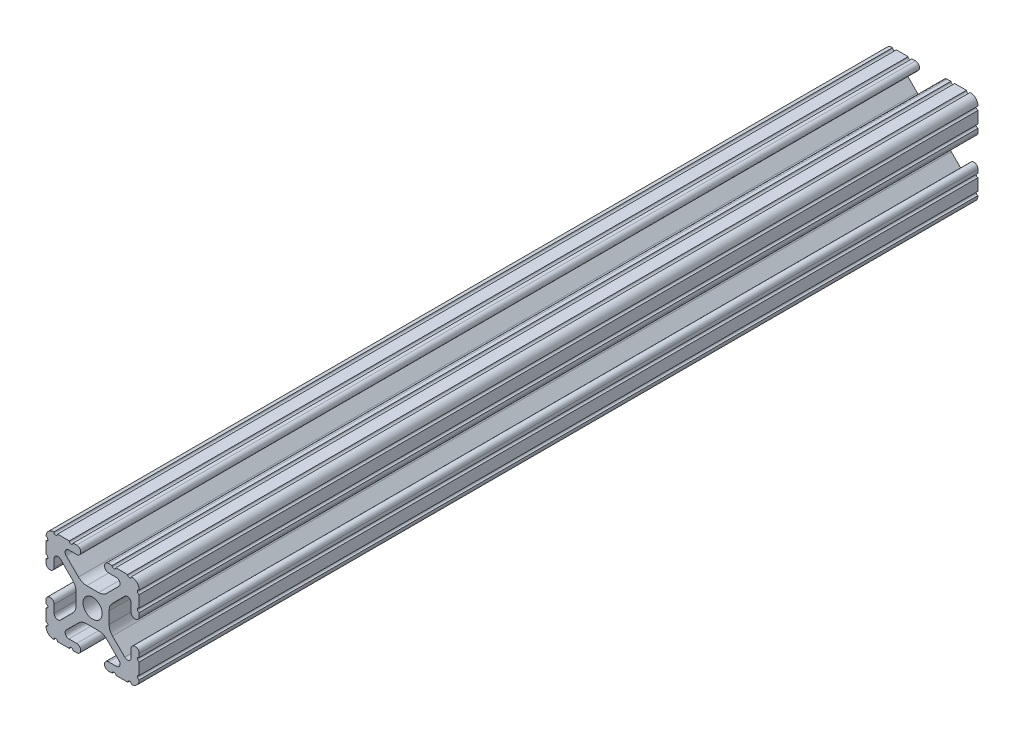
from build123d import *

# Parameters (mm, degrees)
SKETCH1_R           = 2.6035
BOSS_EXTRUDE1_DEPTH = 228.6


with BuildPart() as part:
    # Sketch1 → Boss-Extrude1 (new body)
    with BuildSketch(Plane(origin=(0, 0, -342.9), x_dir=(-1, 0, 0), z_dir=(0, 0, -1))):
        with BuildLine():
            Line((12.7, -9.5504), (12.7, -6.3330836))
            ThreePointArc((12.7, -6.3330836), (12.192, -5.8250836), (12.7, -5.3170836))
            Line((12.7, -5.3170836), (12.7, -4.3434))
            ThreePointArc((12.7, -4.3434), (11.5951, -3.2385), (10.4902, -4.3434))
            Line((10.4902, -4.3434), (10.4902, -6.474794456))
            ThreePointArc((10.4902, -6.474794456), (9.863006367, -7.413456061), (8.75577951, -7.193214945))
            Line((8.75577951, -7.193214945), (5.42573597, -3.863171405))
            ThreePointArc((5.42573597, -3.863171405), (4.737482484, -2.833127272), (4.4958, -1.618107374))
            Line((4.4958, -1.618107374), (4.4958, 1.618107374))
            ThreePointArc((4.4958, 1.618107374), (4.737482484, 2.833127272), (5.42573597, 3.863171405))
            Line((5.42573597, 3.863171405), (8.75577951, 7.193214945))
            ThreePointArc((8.75577951, 7.193214945), (9.863006367, 7.413456061), (10.4902, 6.474794456))
            Line((10.4902, 6.474794456), (10.4902, 4.343399971))
            ThreePointArc((10.4902, 4.343399971), (11.5951, 3.238499971), (12.7, 4.343399971))
            Line((12.7, 4.343399971), (12.7, 5.3170836))
            ThreePointArc((12.7, 5.3170836), (12.192, 5.8250836), (12.7, 6.3330836))
            Line((12.7, 6.3330836), (12.7, 9.5504))
            ThreePointArc((12.7, 9.5504), (12.192000006, 10.058323491), (12.699846982, 10.566399977))
            ThreePointArc((12.699846982, 10.566399977), (12.082522516, 12.082522516), (10.566399977, 12.699846982))
            ThreePointArc((10.566399977, 12.699846982), (10.058323491, 12.192000006), (9.5504, 12.7))
            Line((9.5504, 12.7), (6.3330836, 12.7))
            ThreePointArc((6.3330836, 12.7), (5.8250836, 12.192), (5.3170836, 12.7))
            Line((5.3170836, 12.7), (4.3434, 12.7))
            ThreePointArc((4.3434, 12.7), (3.2385, 11.5951), (4.3434, 10.4902))
            Line((4.3434, 10.4902), (6.474794456, 10.4902))
            ThreePointArc((6.474794456, 10.4902), (7.413456061, 9.863006367), (7.193214945, 8.75577951))
            Line((7.193214945, 8.75577951), (3.863171405, 5.42573597))
            ThreePointArc((3.863171405, 5.42573597), (2.833127272, 4.737482484), (1.618107374, 4.4958))
            Line((1.618107374, 4.4958), (-1.618107374, 4.4958))
            ThreePointArc((-1.618107374, 4.4958), (-2.833127272, 4.737482484), (-3.863171405, 5.42573597))
            Line((-3.863171405, 5.42573597), (-7.193214945, 8.75577951))
            ThreePointArc((-7.193214945, 8.75577951), (-7.413456061, 9.863006367), (-6.474794456, 10.4902))
            Line((-6.474794456, 10.4902), (-4.343399971, 10.4902))
            ThreePointArc((-4.343399971, 10.4902), (-3.238499971, 11.5951), (-4.343399971, 12.7))
            Line((-4.343399971, 12.7), (-5.3170836, 12.7))
            ThreePointArc((-5.3170836, 12.7), (-5.8250836, 12.192), (-6.3330836, 12.7))
            Line((-6.3330836, 12.7), (-9.5504, 12.7))
            ThreePointArc((-9.5504, 12.7), (-10.058323491, 12.192000006), (-10.566399977, 12.699846982))
            ThreePointArc((-10.566399977, 12.699846982), (-12.082522516, 12.082522516), (-12.699846982, 10.566399977))
            ThreePointArc((-12.699846982, 10.566399977), (-12.192000006, 10.058323491), (-12.7, 9.5504))
            Line((-12.7, 9.5504), (-12.7, 6.3330836))
            ThreePointArc((-12.7, 6.3330836), (-12.192, 5.8250836), (-12.7, 5.3170836))
            Line((-12.7, 5.3170836), (-12.7, 4.3434))
            ThreePointArc((-12.7, 4.3434), (-11.5951, 3.2385), (-10.4902, 4.3434))
            Line((-10.4902, 4.3434), (-10.4902, 6.474794456))
            ThreePointArc((-10.4902, 6.474794456), (-9.863006367, 7.413456061), (-8.75577951, 7.193214945))
            Line((-8.75577951, 7.193214945), (-5.42573597, 3.863171405))
            ThreePointArc((-5.42573597, 3.863171405), (-4.737482484, 2.833127272), (-4.4958, 1.618107374))
            Line((-4.4958, 1.618107374), (-4.4958, -1.618107374))
            ThreePointArc((-4.4958, -1.618107374), (-4.737482484, -2.833127272), (-5.42573597, -3.863171405))
            Line((-5.42573597, -3.863171405), (-8.75577951, -7.193214945))
            ThreePointArc((-8.75577951, -7.193214945), (-9.863006367, -7.413456061), (-10.4902, -6.474794456))
            Line((-10.4902, -6.474794456), (-10.4902, -4.343399971))
            ThreePointArc((-10.4902, -4.343399971), (-11.5951, -3.238499971), (-12.7, -4.343399971))
            Line((-12.7, -4.343399971), (-12.7, -5.3170836))
            ThreePointArc((-12.7, -5.3170836), (-12.192, -5.8250836), (-12.7, -6.3330836))
            Line((-12.7, -6.3330836), (-12.7, -9.5504))
            ThreePointArc((-12.7, -9.5504), (-12.192000006, -10.058323491), (-12.699846982, -10.566399977))
            ThreePointArc((-12.699846982, -10.566399977), (-12.082522516, -12.082522516), (-10.566399977, -12.699846982))
            ThreePointArc((-10.566399977, -12.699846982), (-10.058323491, -12.192000006), (-9.5504, -12.7))
            Line((-9.5504, -12.7), (-6.3330836, -12.7))
            ThreePointArc((-6.3330836, -12.7), (-5.8250836, -12.192), (-5.3170836, -12.7))
            Line((-5.3170836, -12.7), (-4.3434, -12.7))
            ThreePointArc((-4.3434, -12.7), (-3.2385, -11.5951), (-4.3434, -10.4902))
            Line((-4.3434, -10.4902), (-6.474794456, -10.4902))
            ThreePointArc((-6.474794456, -10.4902), (-7.413456061, -9.863006367), (-7.193214945, -8.75577951))
            Line((-7.193214945, -8.75577951), (-3.863171405, -5.42573597))
            ThreePointArc((-3.863171405, -5.42573597), (-2.833127272, -4.737482484), (-1.618107374, -4.4958))
            Line((-1.618107374, -4.4958), (1.618107374, -4.4958))
            ThreePointArc((1.618107374, -4.4958), (2.833127272, -4.737482484), (3.863171405, -5.42573597))
            Line((3.863171405, -5.42573597), (7.193214945, -8.75577951))
            ThreePointArc((7.193214945, -8.75577951), (7.413456061, -9.863006367), (6.474794456, -10.4902))
            Line((6.474794456, -10.4902), (4.343399971, -10.4902))
            ThreePointArc((4.343399971, -10.4902), (3.238499971, -11.5951), (4.343399971, -12.7))
            Line((4.343399971, -12.7), (5.3170836, -12.7))
            ThreePointArc((5.3170836, -12.7), (5.8250836, -12.192), (6.3330836, -12.7))
            Line((6.3330836, -12.7), (9.5504, -12.7))
            ThreePointArc((9.5504, -12.7), (10.058323491, -12.192000006), (10.566399977, -12.699846982))
            ThreePointArc((10.566399977, -12.699846982), (12.082522516, -12.082522516), (12.699846982, -10.566399977))
            ThreePointArc((12.699846982, -10.566399977), (12.192000006, -10.058323491), (12.7, -9.5504))
        make_face()
        Circle(SKETCH1_R, mode=Mode.SUBTRACT)
    extrude(amount=-BOSS_EXTRUDE1_DEPTH)


solid = part.part
